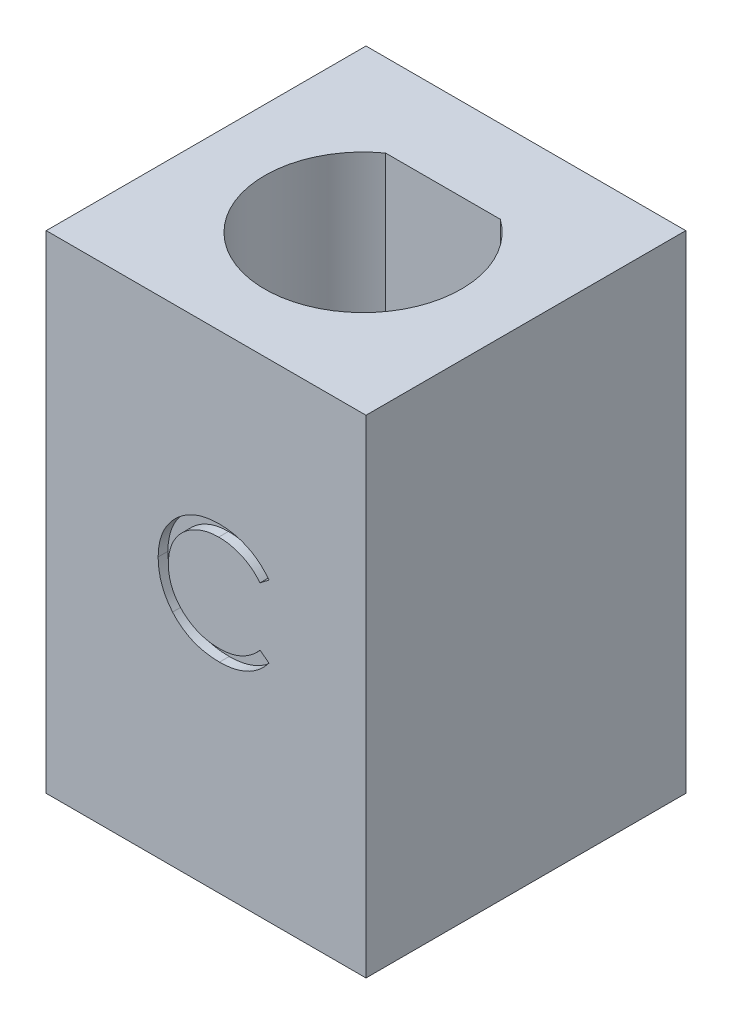
from build123d import *

# Parameters (mm, degrees)
SKETCH1_W           = 9.84142284
SKETCH1_H           = 9.84142284
BOSS_EXTRUDE1_DEPTH = 15
CUT_EXTRUDE1_DEPTH  = 0.3


with BuildPart() as part:
    # Sketch1 → Boss-Extrude1 (new body)
    with BuildSketch(Plane(origin=(0, 0, 0), x_dir=(1, 0, 0), z_dir=(0, 1, 0))):
        Rectangle(SKETCH1_W, SKETCH1_H)
        with BuildLine():
            Line((-1.765045048, 2.369444822), (1.765045048, 2.369444822))
            ThreePointArc((1.765045048, 2.369444822), (0, -3.118257941), (-1.765045048, 2.369444822))
        make_face(mode=Mode.SUBTRACT)
    extrude(amount=BOSS_EXTRUDE1_DEPTH)

    # Sketch2 → Cut-Extrude1 (cut)
    with BuildSketch(Plane.XY.offset(4.92071142)):
        with BuildLine():
            Line((1.934406803, 9.11261109), (1.659567059, 8.902274552))
            add(Edge.make_bspline(
                [(1.659567059, 8.902274552), (1.639961171, 8.925640522), (1.601013724, 8.972057437), (1.538354521, 9.037236982), (1.473052878, 9.098302243), (1.405133757, 9.155544123), (1.333374638, 9.206960889), (1.259513839, 9.255231992), (1.182315794, 9.29849973), (1.075564059, 9.350962716), (0.935916211, 9.405708871), (0.760121372, 9.451612102), (0.576610273, 9.480833278), (0.451412674, 9.483998119), (0.387732123, 9.485607885)],
                knots=[0, 0, 0, 0, 9.1485e-05, 0.000181737, 0.000271024, 0.000359627, 0.000447979, 0.000535687, 0.000624217, 0.000713268, 0.000892422, 0.00107303, 0.001257466, 0.001448389, 0.001448389, 0.001448389, 0.001448389], degree=3))
            add(Edge.make_bspline(
                [(0.387732123, 9.485607885), (0.352648824, 9.485203923), (0.282807831, 9.484399747), (0.179159358, 9.473790622), (0.077446307, 9.458879412), (-0.02226516, 9.436754088), (-0.119848118, 9.408781469), (-0.21594052, 9.375356055), (-0.30915112, 9.334001215), (-0.400769358, 9.288292956), (-0.488548569, 9.236665511), (-0.571603617, 9.180352159), (-0.649631585, 9.119983062), (-0.722694197, 9.055331956), (-0.790866145, 8.986689996), (-0.853653456, 8.913325654), (-0.910838867, 8.83547348), (-0.963555892, 8.754160073), (-1.010768625, 8.669622281), (-1.050298504, 8.581547211), (-1.085303627, 8.491443108), (-1.113002869, 8.398291947), (-1.134927386, 8.302749181), (-1.150055049, 8.204558393), (-1.160543521, 8.103924714), (-1.161343697, 8.035715401), (-1.161747044, 8.001333045)],
                knots=[0, 0, 0, 0, 0.000105206, 0.000209435, 0.000312261, 0.00041348, 0.000515565, 0.000616682, 0.000718413, 0.000821258, 0.000923708, 0.001023662, 0.001122111, 0.001219464, 0.00131614, 0.001412112, 0.001508869, 0.001605718, 0.001702691, 0.001799013, 0.001895107, 0.001992482, 0.002090281, 0.00218895, 0.002290387, 0.00239349, 0.00239349, 0.00239349, 0.00239349], degree=3))
            add(Edge.make_bspline(
                [(-1.161747044, 8.001333045), (-1.160485225, 7.949601726), (-1.15800781, 7.848034141), (-1.135959476, 7.69926353), (-1.102454385, 7.556742856), (-1.052238808, 7.421363014), (-0.990319757, 7.291454656), (-0.912079146, 7.169215803), (-0.821462609, 7.052799238), (-0.717188189, 6.94495629), (-0.602782373, 6.846442565), (-0.480034462, 6.759691983), (-0.349250174, 6.687377101), (-0.211873544, 6.627201155), (-0.06684743, 6.580944427), (0.085567373, 6.548380303), (0.245039368, 6.527138123), (0.354008768, 6.525104435), (0.409466899, 6.524069424)],
                knots=[0, 0, 0, 0, 0.000155106, 0.000304531, 0.000450265, 0.000593548, 0.000736853, 0.000881182, 0.001028026, 0.001178769, 0.001330408, 0.001480379, 0.001628835, 0.001777978, 0.001929641, 0.002084627, 0.002245075, 0.00241136, 0.00241136, 0.00241136, 0.00241136], degree=3))
            add(Edge.make_bspline(
                [(0.409466899, 6.524069424), (0.470569588, 6.525758203), (0.590834297, 6.529082126), (0.767202323, 6.557241375), (0.936038089, 6.602899293), (1.097350675, 6.666797215), (1.250685321, 6.749862503), (1.396281982, 6.850560381), (1.534263552, 6.969848713), (1.617234834, 7.060931842), (1.659567059, 7.107402757)],
                knots=[0, 0, 0, 0, 0.00018322, 0.00036062, 0.000534275, 0.000707044, 0.000879893, 0.001056289, 0.001237208, 0.001425665, 0.001425665, 0.001425665, 0.001425665], degree=3))
            Line((1.659567059, 7.107402757), (1.934406803, 6.899169584))
            add(Edge.make_bspline(
                [(1.934406803, 6.899169584), (1.912288693, 6.870631132), (1.868158417, 6.813690926), (1.7967004, 6.733419216), (1.721423103, 6.65791518), (1.641767393, 6.587787559), (1.558649601, 6.521633094), (1.470577289, 6.461331262), (1.378708257, 6.406040378), (1.283353778, 6.355413454), (1.184615165, 6.310496207), (1.08261073, 6.272042439), (0.977780154, 6.238917549), (0.870118646, 6.211665612), (0.759402889, 6.190394529), (0.646032415, 6.176174854), (0.52976254, 6.166432939), (0.451321119, 6.165545024), (0.411570264, 6.165095065)],
                knots=[0, 0, 0, 0, 0.000108293, 0.000216068, 0.000322162, 0.000427957, 0.000534281, 0.00064066, 0.000747915, 0.000855806, 0.000964371, 0.001073102, 0.001182643, 0.001294024, 0.001406092, 0.001520624, 0.001636667, 0.001755891, 0.001755891, 0.001755891, 0.001755891], degree=3))
            add(Edge.make_bspline(
                [(0.411570264, 6.165095065), (0.373926597, 6.165357057), (0.299490907, 6.165875115), (0.189592155, 6.174267282), (0.082602575, 6.185717019), (-0.021172051, 6.20295715), (-0.122298026, 6.22330149), (-0.219858611, 6.250572747), (-0.314813821, 6.281121914), (-0.406782162, 6.3170269), (-0.495841862, 6.357543083), (-0.581705673, 6.403334642), (-0.664334105, 6.454016507), (-0.744539526, 6.508471517), (-0.82113711, 6.568448819), (-0.894790635, 6.633115453), (-0.965913112, 6.702253464), (-1.009915797, 6.752108317), (-1.032039512, 6.777174392)],
                knots=[0, 0, 0, 0, 0.0001129, 0.000223246, 0.000330481, 0.000435603, 0.000538732, 0.000639764, 0.000739316, 0.000837878, 0.000935767, 0.001032686, 0.001129604, 0.00122645, 0.001323362, 0.001421241, 0.001520399, 0.001620667, 0.001620667, 0.001620667, 0.001620667], degree=3))
            add(Edge.make_bspline(
                [(-1.032039512, 6.777174392), (-1.067475155, 6.82071558), (-1.137918632, 6.907272291), (-1.228044315, 7.047558272), (-1.305191871, 7.194026481), (-1.367567791, 7.34744641), (-1.416330525, 7.507473797), (-1.45011172, 7.674189311), (-1.472063324, 7.847437254), (-1.474573613, 7.965274042), (-1.475849608, 8.025171186)],
                knots=[0, 0, 0, 0, 0.000168306, 0.00033458, 0.000499224, 0.000664315, 0.00083066, 0.00100034, 0.001174094, 0.001353718, 0.001353718, 0.001353718, 0.001353718], degree=3))
            add(Edge.make_bspline(
                [(-1.475849608, 8.025171186), (-1.474294414, 8.08812664), (-1.471234668, 8.211987565), (-1.445238872, 8.393761518), (-1.403420076, 8.567912917), (-1.344023188, 8.734116661), (-1.268717836, 8.893246942), (-1.175691223, 9.044088146), (-1.06602408, 9.187604946), (-0.940576513, 9.321619697), (-0.803009177, 9.44415905), (-0.655690363, 9.551965254), (-0.498908416, 9.64168277), (-0.334390565, 9.716678932), (-0.160904883, 9.774323395), (0.021178486, 9.814676582), (0.211517401, 9.839793698), (0.341379826, 9.842968906), (0.407363533, 9.844582244)],
                knots=[0, 0, 0, 0, 0.000188789, 0.000371431, 0.000549644, 0.000725278, 0.00089996, 0.001076844, 0.001255917, 0.001440951, 0.001626689, 0.001807878, 0.001987546, 0.002167657, 0.002349462, 0.002534866, 0.002726448, 0.002924344, 0.002924344, 0.002924344, 0.002924344], degree=3))
            add(Edge.make_bspline(
                [(0.407363533, 9.844582244), (0.447578005, 9.844100106), (0.527178503, 9.843145762), (0.644931155, 9.83383962), (0.759573482, 9.818326014), (0.871184464, 9.797209944), (0.98030708, 9.771002622), (1.086107321, 9.736862324), (1.189206008, 9.697825793), (1.288952916, 9.652867327), (1.384869466, 9.602400585), (1.476925785, 9.546984962), (1.564390643, 9.486689156), (1.647879492, 9.422025981), (1.725995703, 9.351627422), (1.800957181, 9.277429826), (1.87021826, 9.197296001), (1.912971455, 9.140891068), (1.934406803, 9.11261109)],
                knots=[0, 0, 0, 0, 0.000120626, 0.000238766, 0.000354085, 0.000467531, 0.000579423, 0.000690512, 0.000800803, 0.000910007, 0.001018518, 0.001125773, 0.001232152, 0.001337058, 0.001442329, 0.001547432, 0.001653292, 0.001759736, 0.001759736, 0.001759736, 0.001759736], degree=3))
        make_face()
    extrude(amount=-CUT_EXTRUDE1_DEPTH, mode=Mode.SUBTRACT)


solid = part.part
